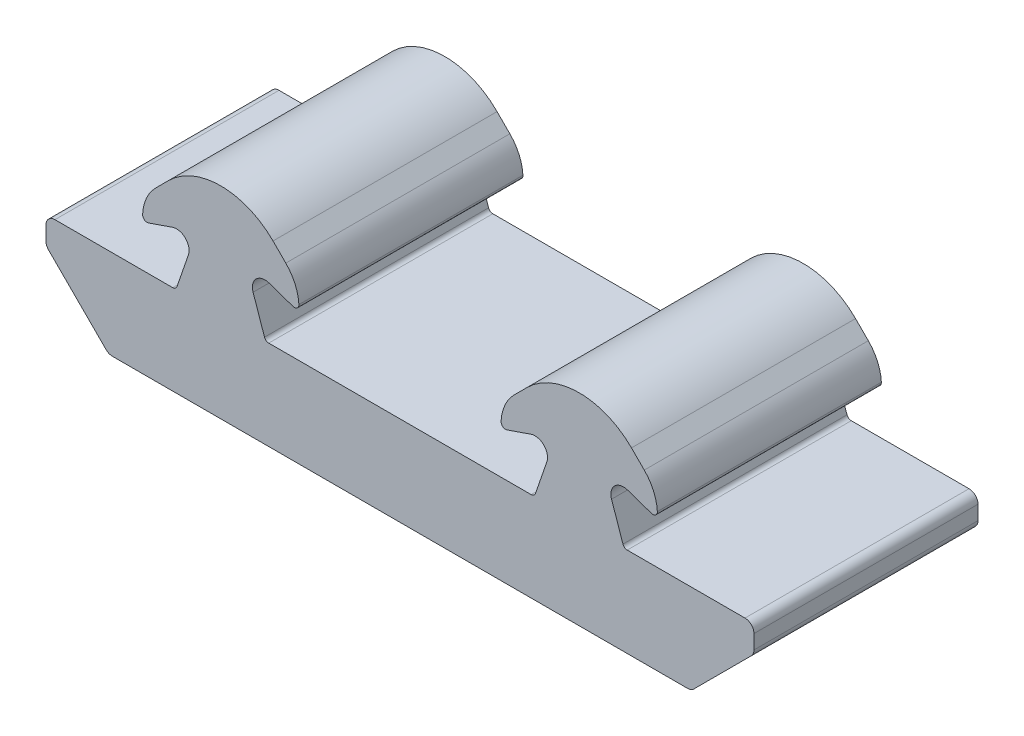
from build123d import *

# Parameters (mm, degrees)
MAIN_EXTRUSION_DEPTH = 25


with BuildPart() as part:
    # Sk Main Extrusion → Main Extrusion (new body)
    with BuildSketch(Plane.XY):
        with BuildLine():
            Line((-38.5, 4.863775977), (-25.356646534, 4.863775977))
            ThreePointArc((-25.356646534, 4.863775977), (-25.066295056, 4.956718218), (-24.883887246, 5.2009919))
            Line((-24.883887246, 5.2009919), (-23.608380992, 8.905331037))
            ThreePointArc((-23.608380992, 8.905331037), (-23.942157504, 10.351075947), (-25.387902414, 10.684852459))
            Line((-25.387902414, 10.684852459), (-28.056395253, 9.766016689))
            ThreePointArc((-28.056395253, 9.766016689), (-28.51978883, 9.839233829), (-28.718532589, 10.264198857))
            ThreePointArc((-28.718532589, 10.264198857), (-28.294243331, 12.040244762), (-27.260533906, 13.545503961))
            Line((-27.260533906, 13.545503961), (-25.833630945, 14.972406922))
            ThreePointArc((-25.833630945, 14.972406922), (-20, 17.388775977), (-14.166369055, 14.972406922))
            Line((-14.166369055, 14.972406922), (-12.739466094, 13.545503961))
            ThreePointArc((-12.739466094, 13.545503961), (-11.705756669, 12.040244762), (-11.281467411, 10.264198857))
            ThreePointArc((-11.281467411, 10.264198857), (-11.48021117, 9.839233829), (-11.943604747, 9.766016689))
            Line((-11.943604747, 9.766016689), (-14.612097586, 10.684852459))
            ThreePointArc((-14.612097586, 10.684852459), (-16.057842496, 10.351075947), (-16.391619008, 8.905331037))
            Line((-16.391619008, 8.905331037), (-15.116112754, 5.2009919))
            ThreePointArc((-15.116112754, 5.2009919), (-14.933704944, 4.956718218), (-14.643353466, 4.863775977))
            Line((-14.643353466, 4.863775977), (14.643353466, 4.863775977))
            ThreePointArc((14.643353466, 4.863775977), (14.933704944, 4.956718218), (15.116112754, 5.2009919))
            Line((15.116112754, 5.2009919), (16.391619008, 8.905331037))
            ThreePointArc((16.391619008, 8.905331037), (16.057842496, 10.351075947), (14.612097586, 10.684852459))
            Line((14.612097586, 10.684852459), (11.943604747, 9.766016689))
            ThreePointArc((11.943604747, 9.766016689), (11.48021117, 9.839233829), (11.281467411, 10.264198857))
            ThreePointArc((11.281467411, 10.264198857), (11.705756669, 12.040244762), (12.739466094, 13.545503961))
            Line((12.739466094, 13.545503961), (14.166369055, 14.972406922))
            ThreePointArc((14.166369055, 14.972406922), (20, 17.388775977), (25.833630945, 14.972406922))
            Line((25.833630945, 14.972406922), (27.260533906, 13.545503961))
            ThreePointArc((27.260533906, 13.545503961), (28.294243331, 12.040244762), (28.718532589, 10.264198857))
            ThreePointArc((28.718532589, 10.264198857), (28.51978883, 9.839233829), (28.056395253, 9.766016689))
            Line((28.056395253, 9.766016689), (25.387902414, 10.684852459))
            ThreePointArc((25.387902414, 10.684852459), (23.942157504, 10.351075947), (23.608380992, 8.905331037))
            Line((23.608380992, 8.905331037), (24.883887246, 5.2009919))
            ThreePointArc((24.883887246, 5.2009919), (25.066295056, 4.956718218), (25.356646534, 4.863775977))
            Line((25.356646534, 4.863775977), (38.5, 4.863775977))
            ThreePointArc((38.5, 4.863775977), (39.207106781, 4.570882758), (39.5, 3.863775977))
            Line((39.5, 3.863775977), (39.5, 2.277989539))
            ThreePointArc((39.5, 2.277989539), (39.423879533, 1.895306107), (39.207106781, 1.570882758))
            Line((39.207106781, 1.570882758), (32.792893219, -4.843330804))
            ThreePointArc((32.792893219, -4.843330804), (32.46846987, -5.060103556), (32.085786438, -5.136224023))
            Line((32.085786438, -5.136224023), (-32.085786438, -5.136224023))
            ThreePointArc((-32.085786438, -5.136224023), (-32.46846987, -5.060103556), (-32.792893219, -4.843330804))
            Line((-32.792893219, -4.843330804), (-39.207106781, 1.570882758))
            ThreePointArc((-39.207106781, 1.570882758), (-39.423879533, 1.895306107), (-39.5, 2.277989539))
            Line((-39.5, 2.277989539), (-39.5, 3.863775977))
            ThreePointArc((-39.5, 3.863775977), (-39.207106781, 4.570882758), (-38.5, 4.863775977))
        make_face()
    extrude(amount=-MAIN_EXTRUSION_DEPTH)


solid = part.part
